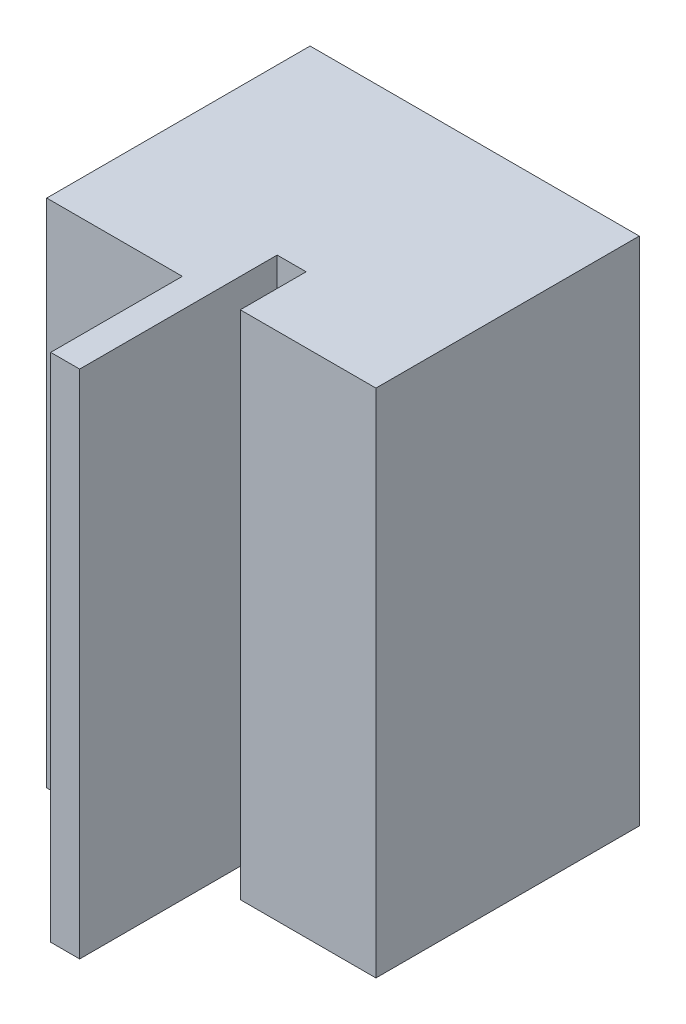
from build123d import *

# Parameters (mm, degrees)
SKETCH_1_W          = 25
SKETCH_1_H          = 20
EXTRUDE_1_DEPTH     = 38.8
SKETCH_3_W          = 4.4
SKETCH_3_H          = 10
EXTRUDE_2_DEPTH     = 38.8
SKETCH_5_W          = 15
SKETCH_5_H          = 38.8
CUT_EXTRUDE_2_DEPTH = 2.2


with BuildPart() as part:
    # 草圖1 → 填料-伸長1 (new body)
    with BuildSketch(Plane(origin=(0, 0, 0), x_dir=(1, 0, 0), z_dir=(0, 1, 0))):
        Rectangle(SKETCH_1_W, SKETCH_1_H)
    extrude(amount=EXTRUDE_1_DEPTH)

    # 草圖3 → 填料-伸長2 (add)
    with BuildSketch(Plane(origin=(0, 38.8, 0), x_dir=(1, 0, 0), z_dir=(0, 1, 0))):
        with Locations((0, -15)):
            Rectangle(SKETCH_3_W, SKETCH_3_H)
    extrude(amount=-EXTRUDE_2_DEPTH)

    # 草圖5 → 除料-伸長2 (cut)
    with BuildSketch(Plane(origin=(2.2, 0, 0), x_dir=(0, 0, -1), z_dir=(1, 0, 0))):
        with Locations((-12.5, 19.4)):
            Rectangle(SKETCH_5_W, SKETCH_5_H)
    extrude(amount=-CUT_EXTRUDE_2_DEPTH, mode=Mode.SUBTRACT)


solid = part.part
